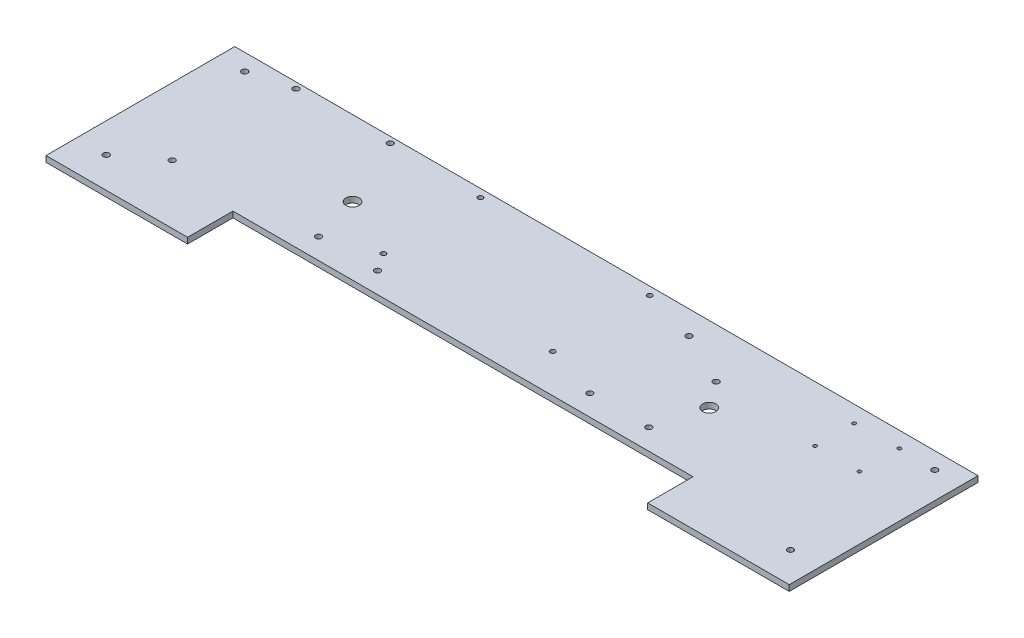
from build123d import *

# Parameters (mm, degrees)
BOSS_EXTRUDE1_DEPTH = 6.35
SKETCH3_R           = 3.302
SKETCH3_R_2         = 3.175
SKETCH3_R_3         = 7.14375
SKETCH3_R_4         = 1.905
CUT_EXTRUDE1_DEPTH  = 7.62
SKETCH5_R           = 2.667
SKETCH5_R_2         = 3.175
CUT_EXTRUDE2_DEPTH  = 7.62


with BuildPart() as part:
    # Sketch1 → Boss-Extrude1 (new body)
    with BuildSketch(Plane(origin=(0, 0, 0), x_dir=(1, 0, 0), z_dir=(0, 1, 0))):
        Polygon((0, 0), (495.3, 0), (495.3, -48.8188), (647.7, -48.8188), (647.7, 154.3812), (-152.4, 154.3812), (-152.4, -48.8188), (0, -48.8188), align=None)
    extrude(amount=BOSS_EXTRUDE1_DEPTH)

    # Sketch3 → Cut-Extrude1 (cut)
    with BuildSketch(Plane(origin=(0, 6.35, 0), x_dir=(1, 0, 0), z_dir=(0, 1, 0))):
        with Locations((-120.65, -15.7988)):
            Circle(SKETCH3_R)
        with Locations((-80.0608, 14.6304)):
            Circle(SKETCH3_R_2)
        with Locations((-123.825, 136.41832)):
            Circle(SKETCH3_R)
        with Locations((-80.0608, 147.9804)):
            Circle(SKETCH3_R_2)
        with Locations((21.463, 147.9804)):
            Circle(SKETCH3_R_2)
        with Locations((55.626, 73.1012)):
            Circle(SKETCH3_R_3)
        with Locations((619.125, 136.41832)):
            Circle(SKETCH3_R_2)
        with Locations((615.95, -15.7988)):
            Circle(SKETCH3_R_2)
        with Locations((580.009, 137.4648)):
            Circle(SKETCH3_R_4)
        with Locations((532.257, 94.4118)):
            Circle(SKETCH3_R_4)
        with Locations((580.009, 94.4118)):
            Circle(SKETCH3_R_4)
        with Locations((532.257, 136.41832)):
            Circle(SKETCH3_R_4)
        with Locations((439.674, 73.1012)):
            Circle(SKETCH3_R_3)
    extrude(amount=-CUT_EXTRUDE1_DEPTH, mode=Mode.SUBTRACT)

    # Sketch5 → Cut-Extrude2 (cut)
    with BuildSketch(Plane(origin=(0, 6.35, 0), x_dir=(1, 0, 0), z_dir=(0, 1, 0))):
        with Locations((120.65, 145.7452)):
            Circle(SKETCH5_R)
        with Locations((120.65, 41.3512)):
            Circle(SKETCH5_R)
        with Locations((419.1, 101.0412)):
            Circle(SKETCH5_R_2)
        with Locations((425.45, 22.3012)):
            Circle(SKETCH5_R_2)
        with Locations((361.95, 128.9812)):
            Circle(SKETCH5_R_2)
        with Locations((361.95, 22.3012)):
            Circle(SKETCH5_R_2)
        with Locations((302.9204, 145.7452)):
            Circle(SKETCH5_R)
        with Locations((302.9204, 41.3512)):
            Circle(SKETCH5_R)
        with Locations((133.35, 22.3012)):
            Circle(SKETCH5_R_2)
        with Locations((69.85, 22.3012)):
            Circle(SKETCH5_R_2)
    extrude(amount=-CUT_EXTRUDE2_DEPTH, mode=Mode.SUBTRACT)


solid = part.part
